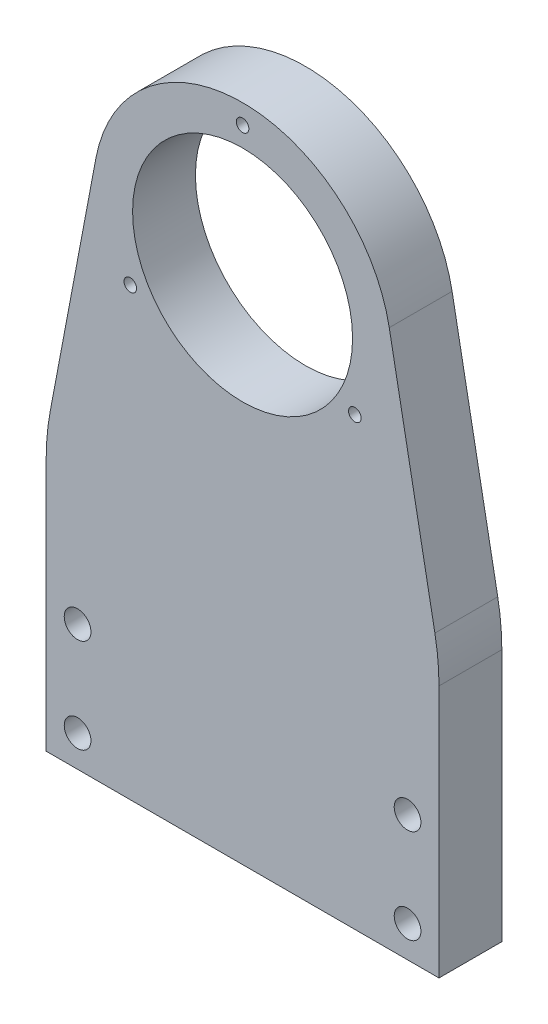
from build123d import *

# Parameters (mm, degrees)
EXTRUDE_1_DEPTH              = 8
FILLET_1_R                   = 30
CUT_EXTRUDE_1_REACH          = 10
SKETCH_2_R                   = 14
HOLE_WIZARD_M3_1_D           = 3.4
HOLE_WIZARD_M3_1_DEPTH       = 8
HOLE_WIZARD_M3_1_CSINK_D     = 6.72
HOLE_WIZARD_M3_1_CSINK_ANGLE = 90
HOLE_WIZARD_M3_1_2_D         = 2.5
HOLE_WIZARD_M3_1_2_DEPTH     = 8.5
HOLE_WIZARD_M3_1_2_TIP       = 0.751075774
HOLE_WIZARD_M2_1_D           = 1.6


with BuildPart() as part:
    # 스케치1 → 보스-돌출1 (new body)
    with BuildSketch(Plane.XY):
        with BuildLine():
            Line((0, 35), (0, 0))
            Line((0, 0), (50, 0))
            Line((50, 0), (50, 35))
            Line((50, 35), (43.670126691, 68.525105576))
            ThreePointArc((43.670126691, 68.525105576), (25, 84), (6.329873309, 68.525105576))
            Line((6.329873309, 68.525105576), (0, 35))
        make_face()
    extrude(amount=EXTRUDE_1_DEPTH)

    # 필렛1
    fillet_1_edges = [part.edges().sort_by_distance(p)[0] for p in [
        (50, 35, 4),
        (0, 35, 4),
    ]]
    fillet(fillet_1_edges, radius=FILLET_1_R)

    # 스케치2 → 컷-돌출1 (cut, up to next)
    with BuildSketch(Plane(origin=(0, 0, 0), x_dir=(-1, 0, 0), z_dir=(0, 0, -1)), mode=Mode.PRIVATE) as cut_extrude_1_sk1:
        with Locations((-25, 65)):
            Circle(SKETCH_2_R)
    cut_extrude_1_tool1 = extrude(cut_extrude_1_sk1.sketch, amount=-CUT_EXTRUDE_1_REACH, mode=Mode.PRIVATE) & part.part
    add(cut_extrude_1_tool1.solids().sort_by_distance((25, 65, 0))[0], mode=Mode.SUBTRACT)

    # Hole Wizard M3 _ _ _ _ _ _ _1
    with Locations(Plane(origin=(0, 0, 0), x_dir=(-1, 0, 0), z_dir=(0, 0, -1))):
        with Locations((-4, 16), (-4, 4), (-46, 16), (-46, 4)):
            CounterSinkHole(HOLE_WIZARD_M3_1_D / 2, HOLE_WIZARD_M3_1_CSINK_D / 2, depth=HOLE_WIZARD_M3_1_DEPTH, counter_sink_angle=HOLE_WIZARD_M3_1_CSINK_ANGLE)

    # Hole Wizard M3 _ _1 2
    with Locations(Plane(origin=(0, 0, 0), x_dir=(-1, 0, 0), z_dir=(0, -1, 0))):
        with Locations((-38, -4), (-12, -4)):
            Hole(HOLE_WIZARD_M3_1_2_D / 2, depth=HOLE_WIZARD_M3_1_2_DEPTH)
            with Locations((0, 0, -(HOLE_WIZARD_M3_1_2_DEPTH + HOLE_WIZARD_M3_1_2_TIP / 2))):  # 118° drill point
                Cone(0, HOLE_WIZARD_M3_1_2_D / 2, HOLE_WIZARD_M3_1_2_TIP, mode=Mode.SUBTRACT)

    # M2 나사 구멍1 (through all)
    with Locations(Plane(origin=(0, 0, 0), x_dir=(-1, 0, 0), z_dir=(0, 0, -1))):
        with Locations((-10.710580838, 56.75), (-25, 81.5), (-39.289419162, 56.75)):
            Hole(HOLE_WIZARD_M2_1_D / 2)


solid = part.part
